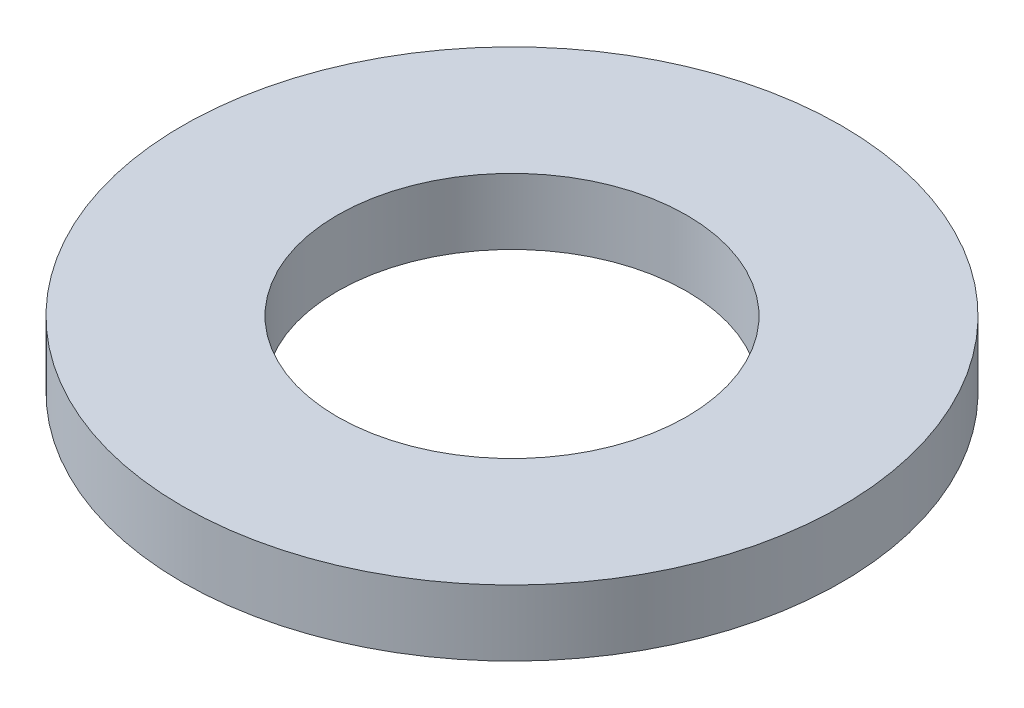
from build123d import *

# Parameters (mm, degrees)
SKETCH1_R      = 5
SKETCH1_R_2    = 2.65
EXTRUDE1_DEPTH = 1


with BuildPart() as part:
    # Sketch1 → Extrude1 (new body)
    with BuildSketch(Plane(origin=(0, 0, 0), x_dir=(1, 0, 0), z_dir=(0, 1, 0))):
        with Locations(Location((0, 0, 0), (0, 0, 270))):  # turned: the seam where the file's is
            Circle(SKETCH1_R)
        with Locations(Location((0, 0, 0), (0, 0, 270))):  # turned: the seam where the file's is
            Circle(SKETCH1_R_2, mode=Mode.SUBTRACT)
    extrude(amount=EXTRUDE1_DEPTH)


solid = part.part
